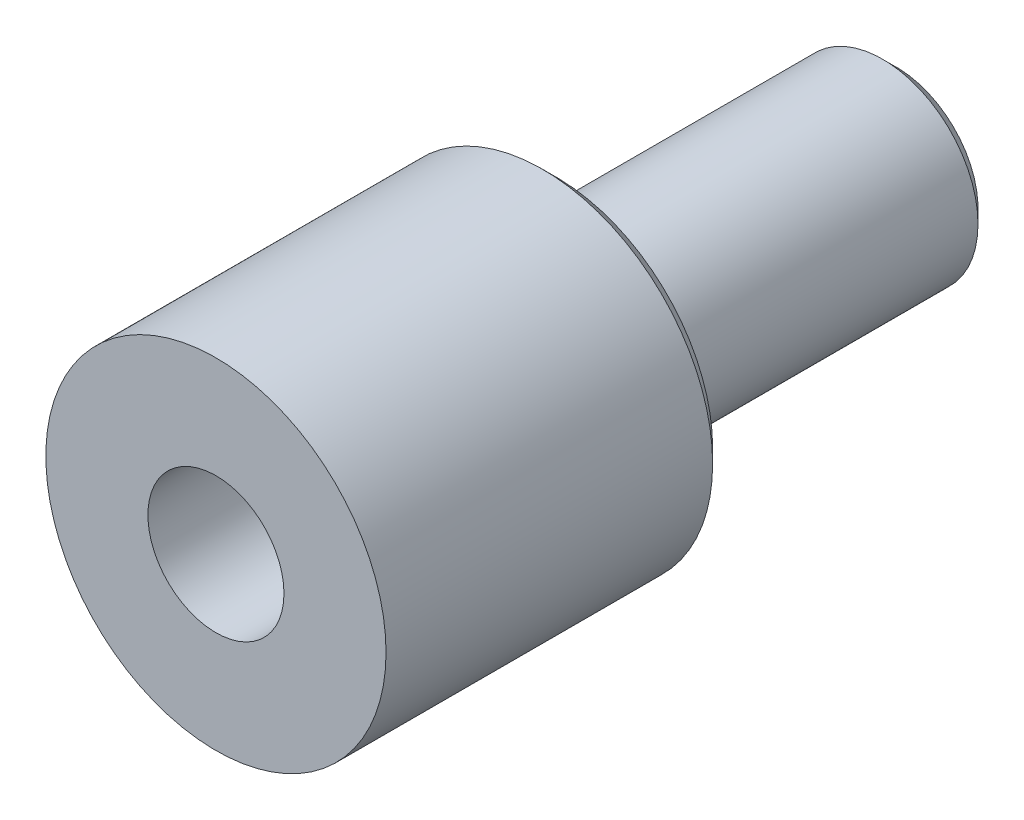
from build123d import *

# Parameters (mm, degrees)
SKETCH1_R           = 12.5
SKETCH1_R_2         = 5
BOSS_EXTRUDE1_DEPTH = 25
SKETCH3_R           = 7
BOSS_EXTRUDE2_DEPTH = 25
CHAMFER1_SIZE       = 1
CHAMFER2_SIZE       = 1


with BuildPart() as part:
    # Sketch1 → Boss-Extrude1 (new body)
    with BuildSketch(Plane.XY):
        Circle(SKETCH1_R)
        Circle(SKETCH1_R_2, mode=Mode.SUBTRACT)
    extrude(amount=BOSS_EXTRUDE1_DEPTH)

    # Sketch3 → Boss-Extrude2 (add)
    with BuildSketch(Plane(origin=(0, 0, 0), x_dir=(-1, 0, 0), z_dir=(0, 0, -1))):
        Circle(SKETCH3_R)
    extrude(amount=BOSS_EXTRUDE2_DEPTH)

    # Chamfer1
    chamfer1_edges = [part.edges().sort_by_distance(p)[0] for p in [
        (-12.5, 0, 0),
    ]]
    chamfer(chamfer1_edges, length=CHAMFER1_SIZE)

    # Chamfer2
    chamfer2_edges = [part.edges().sort_by_distance(p)[0] for p in [
        (7, 0, -25),
    ]]
    chamfer(chamfer2_edges, length=CHAMFER2_SIZE)


solid = part.part
